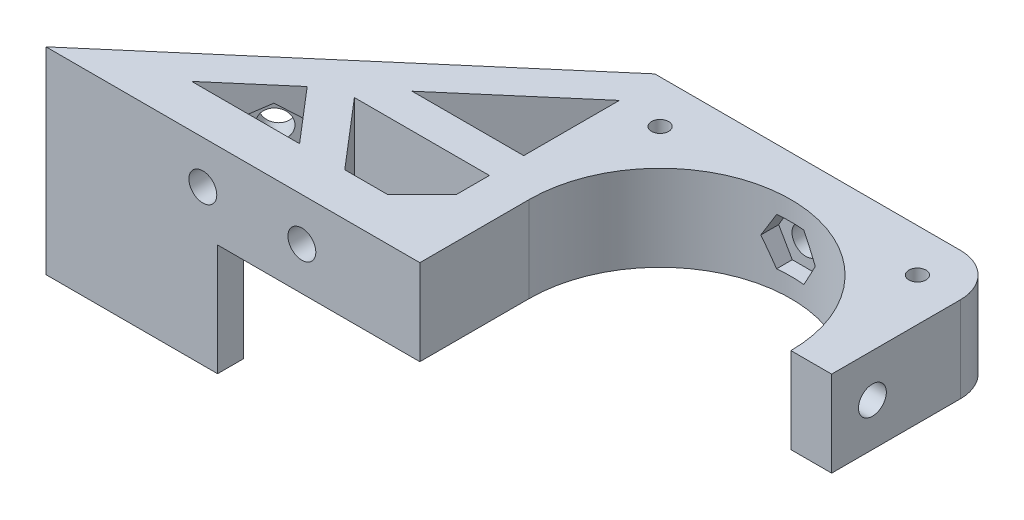
from build123d import *

# Parameters (mm, degrees)
CROQUIS1_R                              = 15.25
CROQUIS1_R_2                            = 2.125
SOPORTE_CAJA_REDUCTORA_DEPTH            = 20
CROQUIS3_R                              = 2.125
CORTAR_EXTRUIR1_DEPTH                   = 51.423828692
REDONDEO1_R                             = 5
BOSS_EXTRUDE1_DEPTH                     = 20
CUT_EXTRUDE1_REACH                      = 55.852
SKETCH2_R                               = 1.625
CUT_EXTRUDE2_DEPTH                      = 2
SKETCH4_R                               = 1.625
CUT_EXTRUDE3_DEPTH                      = 63.291652731
CUT_EXTRUDE4_START                      = -4.5
CUT_EXTRUDE4_DEPTH                      = 2
CROQUIS6_W                              = 4.75
CROQUIS6_H                              = 4.75
CORTAR_EXTRUIR17_DEPTH                  = 42.231056256
CROQUIS7_W                              = 60
CROQUIS7_H                              = 20
CORTAR_EXTRUIR18_DEPTH                  = 51.423828692
SALIENTE_EXTRUIR2_DEPTH                 = 49
SOPORTE_START                           = -15
SOPORTE_MOTOR_DEPTH                     = 15
CROQUIS12_R                             = 2.125
AGUJEROS_DE_SUJECION_A_BASE_DEPTH       = 84.087679592
TUERCA_START                            = -4
TUERCA_AGUJERO_DE_SUJECION_A_BASE_DEPTH = 10
SALIENTE_EXTRUIR4_DEPTH                 = 15
CORTAR_EXTRUIR19_DEPTH                  = 25
CROQUIS14_W                             = 50
CROQUIS14_H                             = 118
CORTAR_EXTRUIR22_DEPTH                  = 146.556045907
CROQUIS15_W                             = 10
CROQUIS15_H                             = 7
CORTAR_EXTRUIR23_DEPTH                  = 42.231056256
CORTAR_EXTRUIR24_DEPTH                  = 42.231056256
CROQUIS18_W                             = 40
CROQUIS18_H                             = 10
CORTAR_EXTRUIR25_DEPTH                  = 44.27311521
SALIENTE_EXTRUIR5_DEPTH                 = 10
CROQUIS20_R                             = 1
CORTAR_EXTRUIR26_DEPTH                  = 49.229270158
CORTAR_EXTRUIR27_REACH                  = 62.959
CORTAR_EXTRUIR27_END_RADIUS             = 15.25
CROQUIS21_R                             = 1.625
CROQUIS22_R                             = 2.125
CROQUIS22_R_2                           = 1
SALIENTE_EXTRUIR6_DEPTH                 = 10
CROQUIS23_R                             = 1.625
CORTAR_EXTRUIR28_DEPTH                  = 52.269508521
CORTAR_EXTRUIR29_START                  = -3
CORTAR_EXTRUIR29_DEPTH                  = 10
SALIENTE_EXTRUIR7_DEPTH                 = 10
CORTAR_EXTRUIR30_REACH                  = 72.235
CROQUIS27_R                             = 1.625
CORTAR_EXTRUIR31_REACH                  = 75.235
CORTAR_EXTRUIR31_START                  = -3
CORTAR_EXTRUIR32_REACH                  = 58.612
CROQUIS29_R                             = 1.625
CORTAR_EXTRUIR33_REACH                  = 61.112
CORTAR_EXTRUIR33_START                  = -2.5
CROQUIS35_W                             = 13.305418987
CROQUIS35_H                             = 6.826864192
CORTAR_EXTRUIR34_DEPTH                  = 63.931555098
CORTAR_EXTRUIR34_DEPTH_BACK             = 63.931555098
CORTAR_EXTRUIR35_START                  = -3
CORTAR_EXTRUIR35_DEPTH                  = 10
SALIENTE_EXTRUIR8_DEPTH                 = 10
SALIENTE_EXTRUIR9_DEPTH                 = 13
SALIENTE_EXTRUIR10_DEPTH                = 3


with BuildPart() as part:
    # Croquis1 → Soporte caja reductora (new body)
    with BuildSketch(Plane(origin=(0, 0, 0), x_dir=(1, 0, 0), z_dir=(0, 1, 0))):
        Polygon((-30, -15.25), (-20, -15.25), (-20, -20), (20, -20), (20, -15.25), (30, -15.25), (30, -7.25), (20, -4.25), (20, 20), (-20, 20), (-20, -4.25), (-30, -7.25), align=None)
        with Locations(Location((0, 0, 0), (0, 0, 270))):
            Circle(CROQUIS1_R, mode=Mode.SUBTRACT)
        with Locations(Location((-15, 15, 0), (0, 0, 270))):
            Circle(CROQUIS1_R_2, mode=Mode.SUBTRACT)
        with Locations(Location((15, 15, 0), (0, 0, 270))):
            Circle(CROQUIS1_R_2, mode=Mode.SUBTRACT)
    extrude(amount=-SOPORTE_CAJA_REDUCTORA_DEPTH)

    # Croquis3 → Cortar-Extruir1 (cut, through all)
    with BuildSketch(Plane.XY.offset(15.25)):
        with Locations((-23.5, -10)):
            Circle(CROQUIS3_R)
        with Locations((23.5, -10)):
            Circle(CROQUIS3_R)
    extrude(amount=-CORTAR_EXTRUIR1_DEPTH, mode=Mode.SUBTRACT)

    # Redondeo1
    redondeo1_edges = [part.edges().sort_by_distance(p)[0] for p in [
        (-20, -10, -20),
        (20, -10, -20),
    ]]
    fillet(redondeo1_edges, radius=REDONDEO1_R)

    # Sketch1 → Boss-Extrude1 (add)
    with BuildSketch(Plane(origin=(0, 0, 0), x_dir=(1, 0, 0), z_dir=(0, 1, 0))):
        with BuildLine():
            Line((25.5, 15), (20, 15))
            ThreePointArc((20, 15), (18.535533906, 18.535533906), (15, 20))
            Line((15, 20), (30, 20))
            Line((30, 20), (30, 8))
            Line((30, 8), (25.5, 8))
            Line((25.5, 8), (25.5, 15))
        make_face()
    extrude(amount=-BOSS_EXTRUDE1_DEPTH)

    # Sketch2 → Cut-Extrude1 (cut, up to next)
    with BuildSketch(Plane(origin=(0, 0, -20), x_dir=(-1, 0, 0), z_dir=(0, 0, -1)), mode=Mode.PRIVATE) as cut_extrude1_sk1:
        with Locations((-22.75, -10)):
            Circle(SKETCH2_R)
    cut_extrude1_tool1 = extrude(cut_extrude1_sk1.sketch, amount=-CUT_EXTRUDE1_REACH, mode=Mode.PRIVATE) & part.part
    add(cut_extrude1_tool1.solids().sort_by_distance((22.75, -10, -20))[0], mode=Mode.SUBTRACT)

    # Sketch3 → Cut-Extrude2 (cut)
    with BuildSketch(Plane.XY.offset(-15)):
        Polygon((20, -11.58771324), (22.75, -13.175426481), (25.5, -11.58771324), (25.5, -8.41228676), (22.75, -6.824573519), (20, -8.41228676), align=None)
    extrude(amount=-CUT_EXTRUDE2_DEPTH, mode=Mode.SUBTRACT)

    # Sketch4 → Cut-Extrude3 (cut, through all)
    with BuildSketch(Plane.ZY.offset(-25.5)):
        with Locations((-12.25, -10)):
            Circle(SKETCH4_R)
    extrude(amount=-CUT_EXTRUDE3_DEPTH, mode=Mode.SUBTRACT)

    # Sketch5 → Cut-Extrude4 (cut)
    with BuildSketch(Plane(origin=(30, 0, 0), x_dir=(0, 0, -1), z_dir=(1, 0, 0)).offset(CUT_EXTRUDE4_START)):
        Polygon((15, -11.58771324), (15, -8.41228676), (12.25, -6.824573519), (9.5, -8.41228676), (9.5, -11.58771324), (12.25, -13.175426481), align=None)
    extrude(amount=CUT_EXTRUDE4_DEPTH, mode=Mode.SUBTRACT)

    # Croquis6 → Cortar-Extruir17 (cut, through all)
    with BuildSketch(Plane(origin=(0, 0, 0), x_dir=(1, 0, 0), z_dir=(0, 1, 0))):
        Polygon((0, -15.25), (-15.25, -15.25), (-15.25, -20), (15.25, -20), (15.25, -15.25), align=None)
        with Locations((-17.625, -17.625)):
            Rectangle(CROQUIS6_W, CROQUIS6_H)
        with BuildLine():
            ThreePointArc((0, -15.25), (-10.783378413, -10.783378413), (-15.25, 0))
            Line((-15.25, 0), (-15.25, -15.25))
            Line((-15.25, -15.25), (0, -15.25))
        make_face()
        with BuildLine():
            Line((15.25, -15.25), (15.25, 0))
            ThreePointArc((15.25, 0), (10.783378413, -10.783378413), (0, -15.25))
            Line((0, -15.25), (15.25, -15.25))
        make_face()
        with Locations((17.625, -17.625)):
            Rectangle(CROQUIS6_W, CROQUIS6_H)
    extrude(amount=-CORTAR_EXTRUIR17_DEPTH, mode=Mode.SUBTRACT)


with BuildPart() as body_2:
    # Simetría1: mirrored copy
    add(part.part.mirror(Plane.ZX))

    # Croquis8 → Saliente-Extruir2 (add)
    with BuildSketch(Plane(origin=(0, 20, 0), x_dir=(1, 0, 0), z_dir=(0, 1, 0))):
        with BuildLine():
            Line((-12.664515522, 20), (-11.040489496, 13.939052358))
            Line((-11.040489496, 13.939052358), (-10.315162126, 11.232093763))
            ThreePointArc((-10.315162126, 11.232093763), (0, 15.25), (10.315162126, 11.232093763))
            Line((10.315162126, 11.232093763), (10.817418481, 13.87928066))
            Line((10.817418481, 13.87928066), (11.978715476, 20))
            Line((11.978715476, 20), (-12.664515522, 20))
        make_face()
    extrude(amount=SALIENTE_EXTRUIR2_DEPTH)

    # Croquis9 → Soporte motor (add)
    with BuildSketch(Plane(origin=(0, 69, 0), x_dir=(1, 0, 0), z_dir=(0, 1, 0)).offset(SOPORTE_START)):
        with BuildLine():
            Line((-20, 15), (-20, -4.25))
            Line((-20, -4.25), (-30, -7.25))
            Line((-30, -7.25), (-30, -15.25))
            Line((-30, -15.25), (0, -15.25))
            Line((0, -15.25), (0, -14.75))
            ThreePointArc((0, -14.75), (-10.429825023, 10.429825023), (14.75, 0))
            Line((14.75, 0), (20, 0))
            Line((20, 0), (20, 13.936837101))
            Line((20, 13.936837101), (12.664515522, 20))
            Line((12.664515522, 20), (-15, 20))
            ThreePointArc((-15, 20), (-18.535533906, 18.535533906), (-20, 15))
        make_face()
    extrude(amount=-SOPORTE_MOTOR_DEPTH)

    # Croquis12 → Agujeros de sujecion a base (cut, through all)
    with BuildSketch(Plane.XY.offset(15.25)):
        with Locations((-23.5, 46.5)):
            Circle(CROQUIS12_R)
    extrude(amount=-AGUJEROS_DE_SUJECION_A_BASE_DEPTH, mode=Mode.SUBTRACT)

    # Croquis13 → Tuerca Agujero de sujecion a base (cut)
    with BuildSketch(Plane.XY.offset(15.25).offset(TUERCA_START)):
        Polygon((-20, 44.479274058), (-20, 48.520725942), (-23.5, 50.541451884), (-27, 48.520725942), (-27, 44.479274058), (-23.5, 42.458548116), align=None)
    extrude(amount=-TUERCA_AGUJERO_DE_SUJECION_A_BASE_DEPTH, mode=Mode.SUBTRACT)

    # Croquis10 → Saliente-Extruir4 (add)
    with BuildSketch(Plane(origin=(0, 69, 0), x_dir=(1, 0, 0), z_dir=(0, 1, 0))):
        with BuildLine():
            ThreePointArc((10.315162126, 11.232093763), (0, 15.25), (-10.315162126, 11.232093763))
            Line((-10.315162126, 11.232093763), (-10.16850369, 10.684757026))
            ThreePointArc((-10.16850369, 10.684757026), (0, 14.75), (10.16850369, 10.684757026))
            Line((10.16850369, 10.684757026), (10.315162126, 11.232093763))
        make_face()
    extrude(amount=-SALIENTE_EXTRUIR4_DEPTH)

    # Croquis11 → Cortar-Extruir19 (cut)
    with BuildSketch(Plane.XZ):
        with BuildLine():
            Line((15.25, 4.25), (20, 4.25))
            Line((20, 4.25), (21.972856468, 4.84185694))
            ThreePointArc((21.972856468, 4.84185694), (19.948931102, 10.40625523), (16.543503257, 15.25))
            Line((16.543503257, 15.25), (15.25, 15.25))
            Line((15.25, 15.25), (15.25, 4.25))
        make_face()
        with BuildLine():
            Line((21.972856468, 4.84185694), (30, 7.25))
            Line((30, 7.25), (30, 15.25))
            Line((30, 15.25), (16.543503257, 15.25))
            ThreePointArc((16.543503257, 15.25), (19.948931102, 10.40625523), (21.972856468, 4.84185694))
        make_face()
        with BuildLine():
            ThreePointArc((20, -15), (18.535533906, -18.535533906), (15, -20))
            Line((15, -20), (30, -20))
            Line((30, -20), (30, -8))
            Line((30, -8), (25.5, -8))
            Line((25.5, -8), (25.5, -15))
            Line((25.5, -15), (20, -15))
        make_face()
    extrude(amount=-CORTAR_EXTRUIR19_DEPTH, mode=Mode.SUBTRACT)

    # Simetría2: body 2 across face


with BuildPart() as part_1:
    add(part.part)

    # Croquis7 → Cortar-Extruir18 (cut, through all)
    with BuildSketch(Plane(origin=(0, 0, -20), x_dir=(-1, 0, 0), z_dir=(0, 0, -1))):
        with Locations((0, -10)):
            Rectangle(CROQUIS7_W, CROQUIS7_H)
    extrude(amount=-CORTAR_EXTRUIR18_DEPTH, mode=Mode.SUBTRACT)


with BuildPart() as body_2_1:
    add(body_2.part)
    add(body_2.part.mirror(Plane(origin=(-0.229209569, 69, -16.663998028), x_dir=(0, 0, 1), z_dir=(0, 1, 0))))

    # Croquis14 → Cortar-Extruir22 (cut, through all)
    with BuildSketch(Plane.XY.offset(15.25)):
        with Locations((-5, 79)):
            Rectangle(CROQUIS14_W, CROQUIS14_H)
    extrude(amount=-CORTAR_EXTRUIR22_DEPTH, mode=Mode.SUBTRACT)

    # Croquis15 → Cortar-Extruir23 (cut, through all)
    with BuildSketch(Plane.XZ):
        with Locations((-25, 7.75)):
            Rectangle(CROQUIS15_W, CROQUIS15_H)
    extrude(amount=-CORTAR_EXTRUIR23_DEPTH, mode=Mode.SUBTRACT)

    # Croquis16 → Cortar-Extruir24 (cut, through all)
    with BuildSketch(Plane.XZ):
        Polygon((-30, 15.25), (-15.25, 15.25), (-15.25, 12.75), (-20, 12.75), (-20, 11.25), (-30, 11.25), (-30, 12.75), align=None)
    extrude(amount=-CORTAR_EXTRUIR24_DEPTH, mode=Mode.SUBTRACT)

    # Croquis18 → Cortar-Extruir25 (cut, through all)
    with BuildSketch(Plane(origin=(0, 0, -20), x_dir=(-1, 0, 0), z_dir=(0, 0, -1))):
        with Locations((0, 5)):
            Rectangle(CROQUIS18_W, CROQUIS18_H)
    extrude(amount=-CORTAR_EXTRUIR25_DEPTH, mode=Mode.SUBTRACT)

    # Croquis19 → Saliente-Extruir5 (add)
    with BuildSketch(Plane(origin=(0, 20, 0), x_dir=(1, 0, 0), z_dir=(0, 1, 0))):
        Polygon((-20, -12.75), (-34, -12.75), (-34, -7.75), (-24, -7.75), (-20, -3.75), align=None)
    extrude(amount=-SALIENTE_EXTRUIR5_DEPTH)

    # Croquis20 → Cortar-Extruir26 (cut, through all)
    with BuildSketch(Plane(origin=(0, 0, 7.75), x_dir=(-1, 0, 0), z_dir=(0, 0, -1))):
        with Locations((29, 15)):
            Circle(CROQUIS20_R)
    extrude(amount=-CORTAR_EXTRUIR26_DEPTH, mode=Mode.SUBTRACT)

    # Cortar-Extruir27: up to this cylinder (the profile starts outside it)
    cortar_extruir27_end = Plane(origin=(0, 15, 0), z_dir=(0, -1, 0)) * Cylinder(CORTAR_EXTRUIR27_END_RADIUS, 157.418, mode=Mode.PRIVATE)
    # Croquis21 → Cortar-Extruir27 (cut, up to the surface)
    with BuildSketch(Plane(origin=(20, 0, 0), x_dir=(0, 0, -1), z_dir=(1, 0, 0)), mode=Mode.PRIVATE) as cortar_extruir27_sk1:
        with Locations((4.75, 15)):
            Circle(CROQUIS21_R)
    cortar_extruir27_tool1 = extrude(cortar_extruir27_sk1.sketch, amount=-CORTAR_EXTRUIR27_REACH, mode=Mode.PRIVATE) - cortar_extruir27_end
    add(cortar_extruir27_tool1.solids().sort_by_distance((20, 15, -4.75))[0], mode=Mode.SUBTRACT)

    # Croquis22 → Saliente-Extruir6 (add)
    with BuildSketch(Plane.XZ.offset(-10)):
        with Locations((-15, -15)):
            Circle(CROQUIS22_R)
        with Locations(Location((-15, -15, 0), (0, 0, 270))):
            Circle(CROQUIS22_R_2, mode=Mode.SUBTRACT)
        with Locations((15, -15)):
            Circle(CROQUIS22_R)
        with Locations(Location((15, -15, 0), (0, 0, 270))):
            Circle(CROQUIS22_R_2, mode=Mode.SUBTRACT)
    extrude(amount=-SALIENTE_EXTRUIR6_DEPTH)

    # Croquis23 → Cortar-Extruir28 (cut, through all)
    with BuildSketch(Plane(origin=(0, 0, -20), x_dir=(-1, 0, 0), z_dir=(0, 0, -1))):
        with Locations((0, 15)):
            Circle(CROQUIS23_R)
    extrude(amount=-CORTAR_EXTRUIR28_DEPTH, mode=Mode.SUBTRACT)

    # Croquis24 → Cortar-Extruir29 (cut)
    with BuildSketch(Plane(origin=(0, 0, -20), x_dir=(-1, 0, 0), z_dir=(0, 0, -1)).offset(CORTAR_EXTRUIR29_START)):
        Polygon((1.58771324, 12.25), (3.175426481, 15), (1.58771324, 17.75), (-1.58771324, 17.75), (-3.175426481, 15), (-1.58771324, 12.25), align=None)
    extrude(amount=-CORTAR_EXTRUIR29_DEPTH, mode=Mode.SUBTRACT)

    # Croquis26 → Saliente-Extruir7 (add)
    with BuildSketch(Plane.XZ.offset(-10)):
        Polygon((-34, 7.75), (-34, 12.75), (-58.825, 12.75), (-39.160527763, -4.104491148), (-20, -4.104491148), (-20, -0.104491148), (-35.732113118, -0.104491148), (-29, 7.75), align=None)
        Polygon((-34.268209086, 7.75), (-39.594516123, 1.535690951), (-46.844874897, 7.75), align=None, mode=Mode.SUBTRACT)
    extrude(amount=-SALIENTE_EXTRUIR7_DEPTH)

    # Croquis27 → Cortar-Extruir30 (cut, up to next)
    with BuildSketch(Plane.XY.offset(12.75), mode=Mode.PRIVATE) as cortar_extruir30_sk1:
        with Locations((-40.544874897, 15)):
            Circle(CROQUIS27_R)
    cortar_extruir30_tool1 = extrude(cortar_extruir30_sk1.sketch, amount=-CORTAR_EXTRUIR30_REACH, mode=Mode.PRIVATE) & body_2_1.part
    # Croquis27 → Cortar-Extruir30 (cut, up to next)
    with BuildSketch(Plane.XY.offset(12.75), mode=Mode.PRIVATE) as cortar_extruir30_sk2:
        with Locations((-29, 15)):
            Circle(CROQUIS27_R)
    cortar_extruir30_tool2 = extrude(cortar_extruir30_sk2.sketch, amount=-CORTAR_EXTRUIR30_REACH, mode=Mode.PRIVATE) & body_2_1.part
    add(cortar_extruir30_tool1.solids().sort_by_distance((-40.544875, 15, 12.75))[0], mode=Mode.SUBTRACT)
    add(cortar_extruir30_tool2.solids().sort_by_distance((-29, 15, 12.75))[0], mode=Mode.SUBTRACT)

    # Croquis28 → Cortar-Extruir31 (cut, up to next)
    with BuildSketch(Plane.XY.offset(12.75).offset(CORTAR_EXTRUIR31_START), mode=Mode.PRIVATE) as cortar_extruir31_sk1:
        Polygon((-38.957161657, 12.25), (-37.369448416, 15), (-38.957161657, 17.75), (-42.132588137, 17.75), (-43.720301378, 15), (-42.132588137, 12.25), align=None)
    cortar_extruir31_tool1 = extrude(cortar_extruir31_sk1.sketch, amount=-CORTAR_EXTRUIR31_REACH, mode=Mode.PRIVATE) & body_2_1.part
    # Croquis28 → Cortar-Extruir31 (cut, up to next)
    with BuildSketch(Plane.XY.offset(12.75).offset(CORTAR_EXTRUIR31_START), mode=Mode.PRIVATE) as cortar_extruir31_sk2:
        Polygon((-27.41228676, 12.25), (-25.824573519, 15), (-27.41228676, 17.75), (-30.58771324, 17.75), (-32.175426481, 15), (-30.58771324, 12.25), align=None)
    cortar_extruir31_tool2 = extrude(cortar_extruir31_sk2.sketch, amount=-CORTAR_EXTRUIR31_REACH, mode=Mode.PRIVATE) & body_2_1.part
    add(cortar_extruir31_tool1.solids().sort_by_distance((-40.544875, 15, 9.75))[0], mode=Mode.SUBTRACT)
    add(cortar_extruir31_tool2.solids().sort_by_distance((-29, 15, 9.75))[0], mode=Mode.SUBTRACT)

    # Croquis29 → Cortar-Extruir32 (cut, up to next)
    with BuildSketch(Plane(origin=(-18.612848159, 0, -21.715982563), x_dir=(-0.7592713073348843, 0, 0.6507742172658468), z_dir=(-0.6507742172658468, 0, -0.7592713073348843)), mode=Mode.PRIVATE) as cortar_extruir32_sk1:
        with Locations((33.812368097, 15)):
            Circle(CROQUIS29_R)
    cortar_extruir32_tool1 = extrude(cortar_extruir32_sk1.sketch, amount=-CORTAR_EXTRUIR32_REACH, mode=Mode.PRIVATE) & body_2_1.part
    add(cortar_extruir32_tool1.solids().sort_by_distance((-44.285609, 15, 0.288235))[0], mode=Mode.SUBTRACT)

    # Croquis31 → Cortar-Extruir33 (cut, up to next)
    with BuildSketch(Plane(origin=(-18.612848159, 0, -21.715982563), x_dir=(-0.7592713073348843, 0, 0.6507742172658468), z_dir=(-0.6507742172658468, 0, -0.7592713073348843)).offset(CORTAR_EXTRUIR33_START), mode=Mode.PRIVATE) as cortar_extruir33_sk1:
        Polygon((36.562368097, 16.58771324), (33.812368097, 18.175426481), (31.062368097, 16.58771324), (31.062368097, 13.41228676), (33.812368097, 11.824573519), (36.562368097, 13.41228676), align=None)
    cortar_extruir33_tool1 = extrude(cortar_extruir33_sk1.sketch, amount=-CORTAR_EXTRUIR33_REACH, mode=Mode.PRIVATE) & body_2_1.part
    add(cortar_extruir33_tool1.solids().sort_by_distance((-42.658674, 15, 2.186413))[0], mode=Mode.SUBTRACT)

    # Croquis35 → Cortar-Extruir34 (cut, two sides)
    with BuildSketch(Plane(origin=(0, 20, 0), x_dir=(1, 0, 0), z_dir=(0, 1, 0))) as cortar_extruir34_sk:
        with Locations((17.04227466, -3.413432096)):
            Rectangle(CROQUIS35_W, CROQUIS35_H)
    extrude(amount=CORTAR_EXTRUIR34_DEPTH, mode=Mode.SUBTRACT)
    extrude(cortar_extruir34_sk.sketch, amount=-CORTAR_EXTRUIR34_DEPTH_BACK, mode=Mode.SUBTRACT)

    # Croquis36 → Cortar-Extruir35 (cut)
    with BuildSketch(Plane(origin=(20, 0, 0), x_dir=(0, 0, -1), z_dir=(1, 0, 0)).offset(CORTAR_EXTRUIR35_START)):
        Polygon((7.5, 16.58771324), (4.75, 18.175426481), (2, 16.58771324), (2, 13.41228676), (4.75, 11.824573519), (7.5, 13.41228676), align=None)
    extrude(amount=-CORTAR_EXTRUIR35_DEPTH, mode=Mode.SUBTRACT)

    # Croquis37 → Saliente-Extruir8 (add)
    with BuildSketch(Plane.XZ.offset(-10)):
        Polygon((-39.160527763, -4.104491148), (-20.614919368, -20), (-15, -20), (-19.558128305, -15.637570403), (-33.014002756, -4.104491148), align=None)
    extrude(amount=-SALIENTE_EXTRUIR8_DEPTH)

    # Croquis38 → Saliente-Extruir9 (add)
    with BuildSketch(Plane.XZ.offset(-10)):
        Polygon((-58.825, 12.75), (-38.825, 12.75), (-38.825, 9.75), (-55.324839942, 9.75), align=None)
    extrude(amount=SALIENTE_EXTRUIR9_DEPTH)

    # Croquis39 → Saliente-Extruir10 (add)
    with BuildSketch(Plane.XZ.offset(-10)):
        Polygon((-38.825, 9.75), (-38.825, 7.75), (-38.825, 5.75), (-50.657959865, 5.75), (-52.991399903, 7.75), (-55.324839942, 9.75), align=None)
    extrude(amount=SALIENTE_EXTRUIR10_DEPTH)


solid = body_2_1.part
